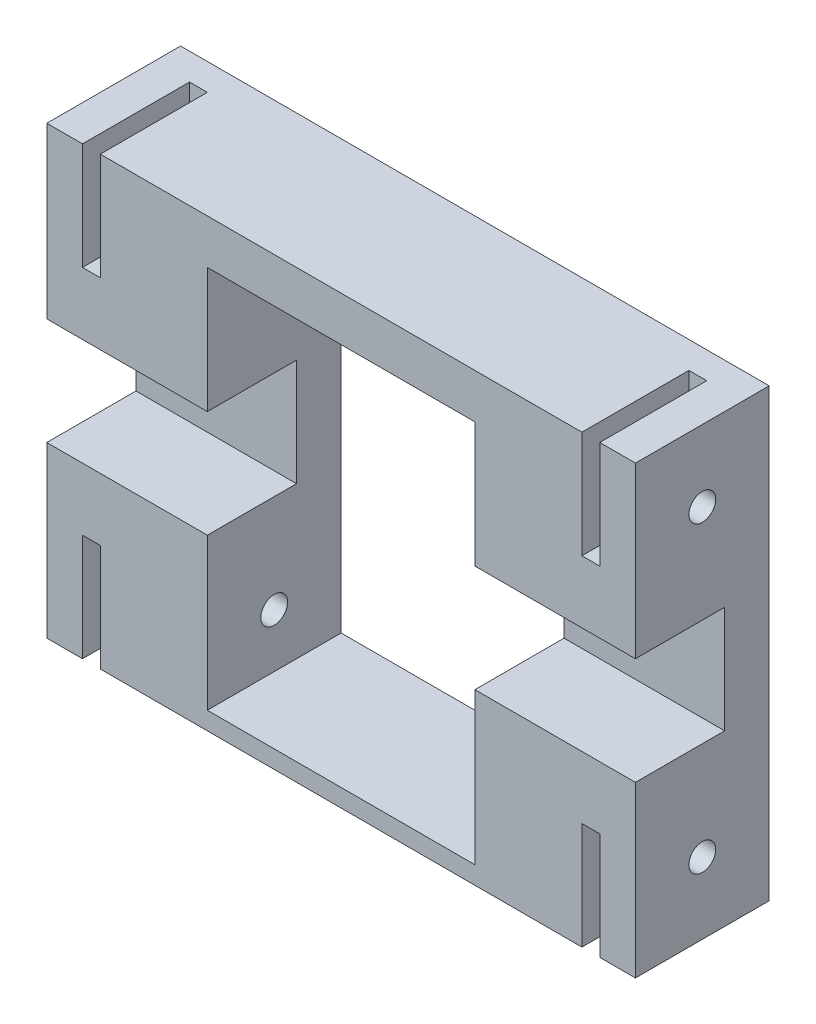
from build123d import *

# Parameters (mm, degrees)
CROQUIS1_W              = 66
CROQUIS1_H              = 50
CROQUIS1_W_2            = 30
CROQUIS1_H_2            = 43
SALIENTE_EXTRUIR1_DEPTH = 15
CROQUIS2_R              = 1.5
CROQUIS2_W              = 10
CROQUIS2_H              = 12
CORTAR_EXTRUIR1_DEPTH   = 67
CROQUIS3_W              = 2
CROQUIS3_H              = 12
CORTAR_EXTRUIR2_DEPTH   = 12


with BuildPart() as part:
    # Croquis1 → Saliente-Extruir1 (new body)
    with BuildSketch(Plane.XY):
        with Locations((33, 25)):
            Rectangle(CROQUIS1_W, CROQUIS1_H)
        with Locations((33, 23.5)):
            Rectangle(CROQUIS1_W_2, CROQUIS1_H_2, mode=Mode.SUBTRACT)
    extrude(amount=SALIENTE_EXTRUIR1_DEPTH)

    # Croquis2 → Cortar-Extruir1 (cut, through all)
    with BuildSketch(Plane.ZY):
        with Locations((7.5, 42)):
            Circle(CROQUIS2_R)
        with Locations((7.5, 8)):
            Circle(CROQUIS2_R)
        with Locations((10, 25)):
            Rectangle(CROQUIS2_W, CROQUIS2_H)
    extrude(amount=-CORTAR_EXTRUIR1_DEPTH, mode=Mode.SUBTRACT)

    # Croquis3 → Cortar-Extruir2 (cut)
    with BuildSketch(Plane.XY.offset(15)):
        with Locations((5, 44)):
            Rectangle(CROQUIS3_W, CROQUIS3_H)
        with Locations((61, 44)):
            Rectangle(CROQUIS3_W, CROQUIS3_H)
        with Locations((5, 6)):
            Rectangle(CROQUIS3_W, CROQUIS3_H)
        with Locations((61, 6)):
            Rectangle(CROQUIS3_W, CROQUIS3_H)
    extrude(amount=-CORTAR_EXTRUIR2_DEPTH, mode=Mode.SUBTRACT)


solid = part.part
